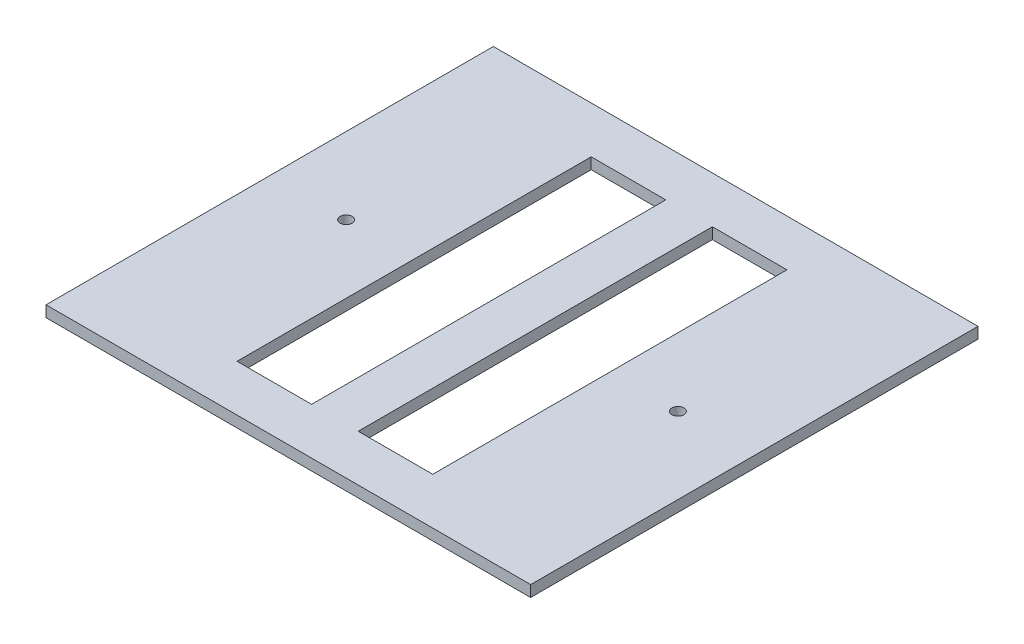
from build123d import *

# Parameters (mm, degrees)
SKETCH1_W           = 130
SKETCH1_H           = 120
BOSS_EXTRUDE1_DEPTH = 3
CUT_EXTRUDE1_START  = -4
SKETCH2_W           = 20
SKETCH2_H           = 95
CUT_EXTRUDE1_DEPTH  = 5
CUT_EXTRUDE2_START  = -4
SKETCH3_R           = 1.6
CUT_EXTRUDE2_DEPTH  = 5


with BuildPart() as part:
    # Sketch1 → Boss-Extrude1 (new body)
    with BuildSketch(Plane(origin=(0, 0, 0), x_dir=(1, 0, 0), z_dir=(0, 1, 0))):
        Rectangle(SKETCH1_W, SKETCH1_H)
    extrude(amount=BOSS_EXTRUDE1_DEPTH)

    # Sketch2 → Cut-Extrude1 (cut)
    with BuildSketch(Plane(origin=(0, 3, 0), x_dir=(1, 0, 0), z_dir=(0, 1, 0)).offset(CUT_EXTRUDE1_START)):
        with Locations((-16.25, 0)):
            Rectangle(SKETCH2_W, SKETCH2_H)
    cut_extrude1 = extrude(amount=CUT_EXTRUDE1_DEPTH, mode=Mode.SUBTRACT)

    # Mirror1: Cut-Extrude1 across plane
    add(cut_extrude1.mirror(Plane(origin=(0, 0, 0), x_dir=(0, 0, 1), z_dir=(1, 0, 0))), mode=Mode.SUBTRACT)

    # Sketch3 → Cut-Extrude2 (cut)
    with BuildSketch(Plane(origin=(0, 3, 0), x_dir=(1, 0, 0), z_dir=(0, 1, 0)).offset(CUT_EXTRUDE2_START)):
        with Locations((44.5, 0)):
            Circle(SKETCH3_R)
    cut_extrude2 = extrude(amount=CUT_EXTRUDE2_DEPTH, mode=Mode.SUBTRACT)

    # Mirror2: Cut-Extrude2 across plane
    add(cut_extrude2.mirror(Plane(origin=(0, 0, 0), x_dir=(0, 0, 1), z_dir=(1, 0, 0))), mode=Mode.SUBTRACT)


solid = part.part
